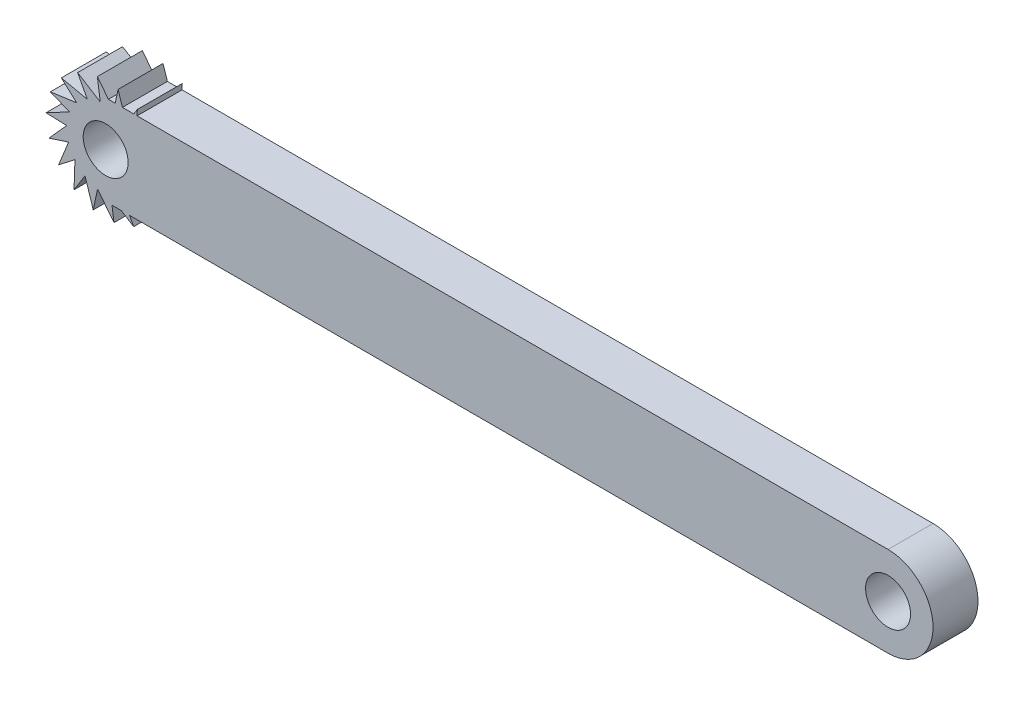
from build123d import *

# Parameters (mm, degrees)
SKETCH1_R                = 10
BOSS_EXTRUDE1_DEPTH      = 20
BOSS_EXTRUDE2_DEPTH      = 20
BOSS_EXTRUDE3_DEPTH      = 10
BOSS_EXTRUDE3_DEPTH_BACK = 15
CUT_EXTRUDE1_DEPTH       = 20
CIRPATTERN1_COUNT        = 18
SKETCH11_R               = 10
CUT_EXTRUDE3_DEPTH       = 33
SKETCH12_R               = 10
CUT_EXTRUDE4_DEPTH       = 5


with BuildPart() as part:
    # Sketch1 → Boss-Extrude1 (new body)
    with BuildSketch(Plane.XY):
        with BuildLine():
            Line((-71.370560529, 20), (276.629439471, 20))
            ThreePointArc((276.629439471, 20), (296.629439471, 0), (276.629439471, -20))
            Line((276.629439471, -20), (-71.370560529, -20))
            ThreePointArc((-71.370560529, -20), (-91.370560529, 0), (-71.370560529, 20))
        make_face()
        with Locations((-71.370560529, 0)):
            Circle(SKETCH1_R, mode=Mode.SUBTRACT)
        with Locations((276.629439471, 0)):
            Circle(SKETCH1_R, mode=Mode.SUBTRACT)
    extrude(amount=BOSS_EXTRUDE1_DEPTH)

    # Sketch2 → Boss-Extrude2 (add)
    with BuildSketch(Plane(origin=(0, 0, 0), x_dir=(-1, 0, 0), z_dir=(0, 0, -1))):
        with BuildLine():
            Line((71.370560529, -20), (71.370560529, -25))
            ThreePointArc((71.370560529, -25), (64.900084402, -24.148145657), (58.870560529, -21.650635095))
            Line((58.870560529, -21.650635095), (62.564306071, -17.956889553))
            ThreePointArc((62.564306071, -17.956889553), (66.850482602, -19.482527955), (71.370560529, -20))
        make_face()
    extrude(amount=BOSS_EXTRUDE2_DEPTH)

    # Sketch6 → Boss-Extrude3 (add, two sides)
    with BuildSketch(Plane.XY.offset(15)) as boss_extrude3_sk:
        Polygon((-65.848114546, 25.970849484), (-62.185743951, 14.6961629), (-57.298605127, 22.515827849), (-57.713272426, 10.668483548), (-50.44638121, 16.345065077), (-54.888071406, 5.354027631), (-46.117922126, 8.20284623), (-54.050901831, -0.606203036), (-44.835303924, -0.928756935), (-55.302738705, -6.49331667), (-46.753229286, -9.948338305), (-58.492592027, -11.597240483), (-51.64036811, -17.768003255), (-63.235718409, -15.302365936), (-58.907259326, -23.444584784), (-68.960026809, -17.161800219), (-67.677408606, -26.293403383), (-74.97508115, -16.951268114), (-76.893006513, -25.970849484), (-80.555377108, -14.6961629), (-85.442515932, -22.515827849), (-85.027848633, -10.668483548), (-92.294739849, -16.345065077), (-87.853049653, -5.354027631), (-96.623198932, -8.20284623), (-88.690219228, 0.606203036), (-97.905817135, 0.928756935), (-87.438382354, 6.49331667), (-95.987891773, 9.948338305), (-84.248529032, 11.597240483), (-91.100752949, 17.768003255), (-79.50540265, 15.302365936), (-83.833861733, 23.444584784), (-73.78109425, 17.161800219), (-75.063712453, 26.293403383), (-67.766039909, 16.951268114), align=None)
    extrude(amount=BOSS_EXTRUDE3_DEPTH)
    extrude(boss_extrude3_sk.sketch, amount=-BOSS_EXTRUDE3_DEPTH_BACK)

    # Sketch10 → Cut-Extrude1 (cut)
    with BuildSketch(Plane.XY.offset(20)):
        with BuildLine():
            Line((-77.019410052, 19.185684743), (-73.78109425, 17.161800219))
            Line((-73.78109425, 17.161800219), (-74.152438156, 19.805583982))
            ThreePointArc((-74.152438156, 19.805583982), (-75.597303819, 19.548264403), (-77.019410052, 19.185684743))
        make_face()
    cut_extrude1 = extrude(amount=-CUT_EXTRUDE1_DEPTH, mode=Mode.SUBTRACT)

    # CirPattern1: Cut-Extrude1 ×18 about axis, 9 skipped
    cirpattern1_axis = Axis((-71.370560529, 0, 20), (0, 0, -1))
    add([cut_extrude1.rotate(cirpattern1_axis, i * 360 / CIRPATTERN1_COUNT) for i in range(1, CIRPATTERN1_COUNT) if i not in (1, 2, 3, 4, 5, 6, 7, 8, 9)], mode=Mode.SUBTRACT)

    # Sketch11 → Cut-Extrude3 (cut)
    with BuildSketch(Plane.XY.offset(25)):
        with Locations((-71.370560529, 0)):
            Circle(SKETCH11_R)
    extrude(amount=-CUT_EXTRUDE3_DEPTH, mode=Mode.SUBTRACT)

    # Sketch12 → Cut-Extrude4 (cut)
    with BuildSketch(Plane.XY.offset(25)):
        Polygon((-97.905817135, 0.928756935), (-88.690219228, 0.606203036), (-96.623198932, -8.20284623), (-87.853049653, -5.354027631), (-92.294739849, -16.345065077), (-85.027848633, -10.668483548), (-85.442515932, -22.515827849), (-80.555377108, -14.6961629), (-76.893006513, -25.970849484), (-74.97508115, -16.951268114), (-67.677408606, -26.293403383), (-68.960026809, -17.161800219), (-58.907259326, -23.444584784), (-63.235718409, -15.302365936), (-51.64036811, -17.768003255), (-58.492592027, -11.597240483), (-46.753229286, -9.948338305), (-55.302738705, -6.49331667), (-44.835303924, -0.928756935), (-54.050901831, -0.606203036), (-46.117922126, 8.20284623), (-54.888071406, 5.354027631), (-50.44638121, 16.345065077), (-57.713272426, 10.668483548), (-57.298605127, 22.515827849), (-62.185743951, 14.6961629), (-65.848114546, 25.970849484), (-67.766039909, 16.951268114), (-75.063712453, 26.293403383), (-73.78109425, 17.161800219), (-83.833861733, 23.444584784), (-79.50540265, 15.302365936), (-91.100752949, 17.768003255), (-84.248529032, 11.597240483), (-95.987891773, 9.948338305), (-87.438382354, 6.49331667), align=None)
        with Locations((-71.370560529, 0)):
            Circle(SKETCH12_R, mode=Mode.SUBTRACT)
    extrude(amount=-CUT_EXTRUDE4_DEPTH, mode=Mode.SUBTRACT)


solid = part.part
